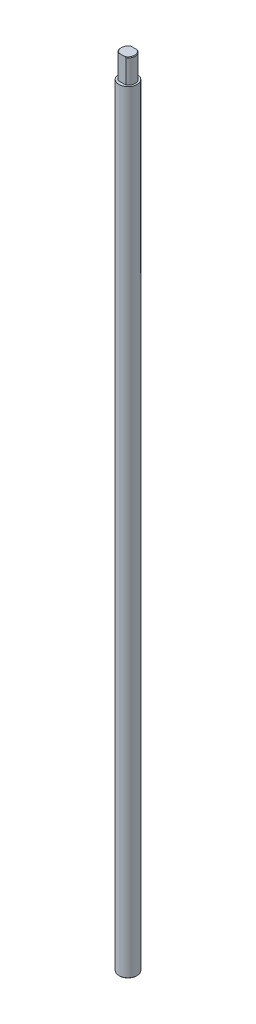
from build123d import *

# Parameters (mm, degrees)
SKETCH1_R               = 7.5
BOSS_EXTRUDE1_DEPTH     = 640
SKETCH2_R               = 6
BOSS_EXTRUDE2_DEPTH     = 20
CHAMFER1_SIZE           = 0.5
CHAMFER2_SIZE           = 0.5
CUT_EXTRUDE1_DEPTH      = 8.5
CUT_EXTRUDE1_DEPTH_BACK = 8.5


with BuildPart() as part:
    # Sketch1 → Boss-Extrude1 (new body)
    with BuildSketch(Plane(origin=(0, 0, 0), x_dir=(1, 0, 0), z_dir=(0, 1, 0))):
        Circle(SKETCH1_R)
    extrude(amount=BOSS_EXTRUDE1_DEPTH)

    # Sketch2 → Boss-Extrude2 (add)
    with BuildSketch(Plane(origin=(0, 640, 0), x_dir=(1, 0, 0), z_dir=(0, 1, 0))):
        Circle(SKETCH2_R)
    extrude(amount=BOSS_EXTRUDE2_DEPTH)

    # Chamfer1
    chamfer1_edges = [part.edges().sort_by_distance(p)[0] for p in [
        (-6, 660, 0),
    ]]
    chamfer(chamfer1_edges, length=CHAMFER1_SIZE)

    # Chamfer2
    chamfer2_edges = [part.edges().sort_by_distance(p)[0] for p in [
        (-7.5, 0, 0),
    ]]
    chamfer(chamfer2_edges, length=CHAMFER2_SIZE)

    # Sketch3 → Cut-Extrude1 (cut, two sides)
    with BuildSketch(Plane(origin=(0, 0, 0), x_dir=(0, 0, -1), z_dir=(1, 0, 0))) as cut_extrude1_sk:
        Polygon((11.720103358, 640), (5, 640), (5, 665.518180004), (13.892257978, 665.518180004), (13.892257978, 640), align=None)
        Polygon((-13.892257978, 640), (-11.720103358, 640), (-5, 640), (-5, 665.518180004), (-13.892257978, 665.518180004), align=None)
    extrude(amount=CUT_EXTRUDE1_DEPTH, mode=Mode.SUBTRACT)
    extrude(cut_extrude1_sk.sketch, amount=-CUT_EXTRUDE1_DEPTH_BACK, mode=Mode.SUBTRACT)


solid = part.part
